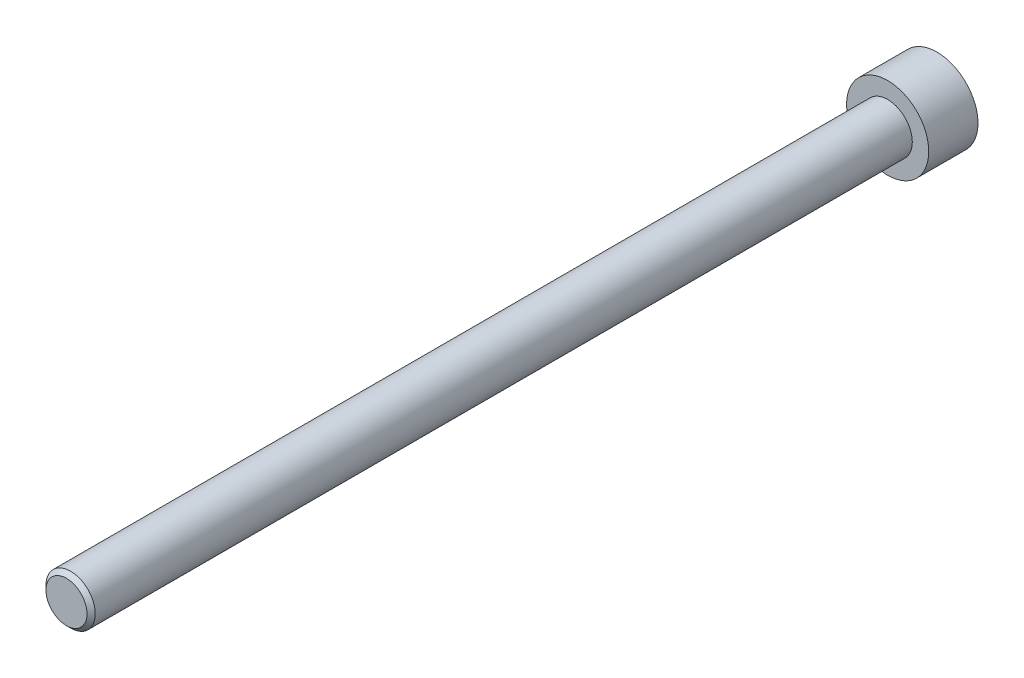
from build123d import *

# Parameters (mm, degrees)
ESQUISSE1_R             = 5
BOSS_EXTRU_1_DEPTH      = 6
ESQUISSE2_R             = 3
BOSS_EXTRU_2_DEPTH      = 100
CHANFREIN1_SIZE         = 0.5
ENL_V_MAT_EXTRU_1_DEPTH = 3.5


with BuildPart() as part:
    # Esquisse1 → Boss.-Extru.1 (new body)
    with BuildSketch(Plane.XY):
        Circle(ESQUISSE1_R)
    extrude(amount=BOSS_EXTRU_1_DEPTH)

    # Esquisse2 → Boss.-Extru.2 (add)
    with BuildSketch(Plane.XY.offset(6)):
        Circle(ESQUISSE2_R)
    extrude(amount=BOSS_EXTRU_2_DEPTH)

    # Chanfrein1
    chanfrein1_edges = [part.edges().sort_by_distance(p)[0] for p in [
        (-3, 0, 106),
    ]]
    chamfer(chanfrein1_edges, length=CHANFREIN1_SIZE)

    # Esquisse3 → Enlèv. mat.-Extru.1 (cut)
    with BuildSketch(Plane(origin=(0, 0, 0), x_dir=(-1, 0, 0), z_dir=(0, 0, -1))):
        Polygon((-1.938814939, -2.138768329), (0.882820236, -2.748447155), (2.821635175, -0.609678826), (1.938814939, 2.138768329), (-0.882820236, 2.748447155), (-2.821635175, 0.609678826), align=None)
    extrude(amount=-ENL_V_MAT_EXTRU_1_DEPTH, mode=Mode.SUBTRACT)


solid = part.part
